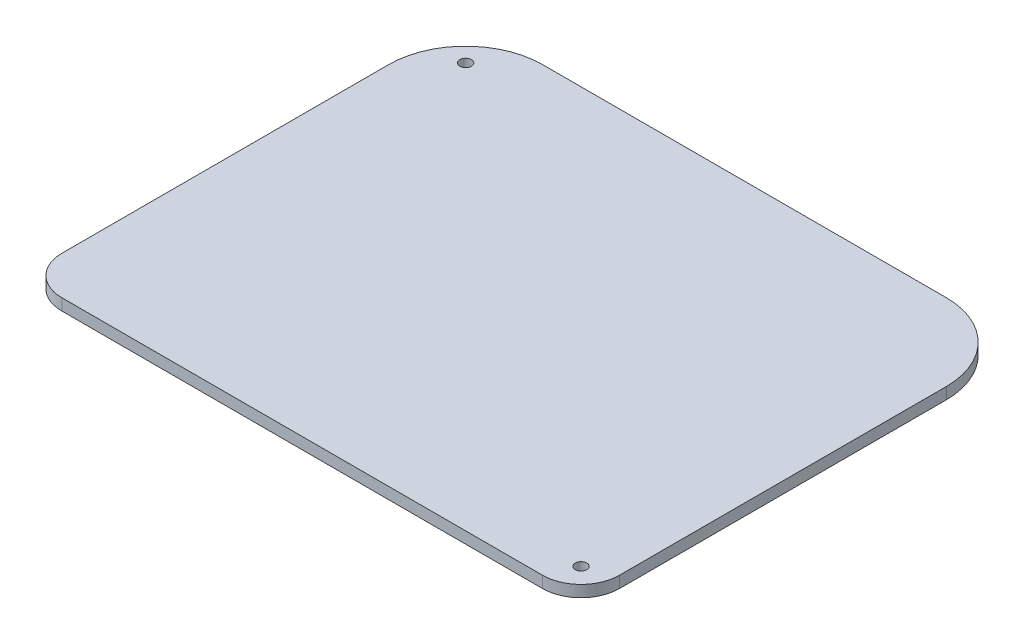
from build123d import *

# Parameters (mm, degrees)
SKETCH1_W           = 145
SKETCH1_H           = 115
BOSS_EXTRUDE1_DEPTH = 3
FILLET1_R           = 10
FILLET2_R           = 20
CUT_EXTRUDE1_REACH  = 5
SKETCH2_R           = 1.5


with BuildPart() as part:
    # Sketch1 → Boss-Extrude1 (new body)
    with BuildSketch(Plane(origin=(0, 0, 0), x_dir=(1, 0, 0), z_dir=(0, 1, 0))):
        Rectangle(SKETCH1_W, SKETCH1_H)
    extrude(amount=BOSS_EXTRUDE1_DEPTH)

    # Fillet1
    fillet1_edges = [part.edges().sort_by_distance(p)[0] for p in [
        (72.5, 1.5, 57.5),
        (-72.5, 1.5, 57.5),
    ]]
    fillet(fillet1_edges, radius=FILLET1_R)

    # Fillet2
    fillet2_edges = [part.edges().sort_by_distance(p)[0] for p in [
        (-72.5, 1.5, -57.5),
        (72.5, 1.5, -57.5),
    ]]
    fillet(fillet2_edges, radius=FILLET2_R)

    # Sketch2 → Cut-Extrude1 (cut, up to next)
    with BuildSketch(Plane.XZ, mode=Mode.PRIVATE) as cut_extrude1_sk1:
        with Locations((65.5, 50.5)):
            Circle(SKETCH2_R)
    cut_extrude1_tool1 = extrude(cut_extrude1_sk1.sketch, amount=-CUT_EXTRUDE1_REACH, mode=Mode.PRIVATE) & part.part
    add(cut_extrude1_tool1.solids().sort_by_distance((65.5, 0, 50.5))[0], mode=Mode.SUBTRACT)
    # Sketch2 → Cut-Extrude1 (cut, up to next)
    with BuildSketch(Plane.XZ, mode=Mode.PRIVATE) as cut_extrude1_sk2:
        with Locations((-62.868103764, -47.867300771)):
            Circle(SKETCH2_R)
    cut_extrude1_tool2 = extrude(cut_extrude1_sk2.sketch, amount=-CUT_EXTRUDE1_REACH, mode=Mode.PRIVATE) & part.part
    add(cut_extrude1_tool2.solids().sort_by_distance((-62.868104, 0, -47.867301))[0], mode=Mode.SUBTRACT)


solid = part.part
